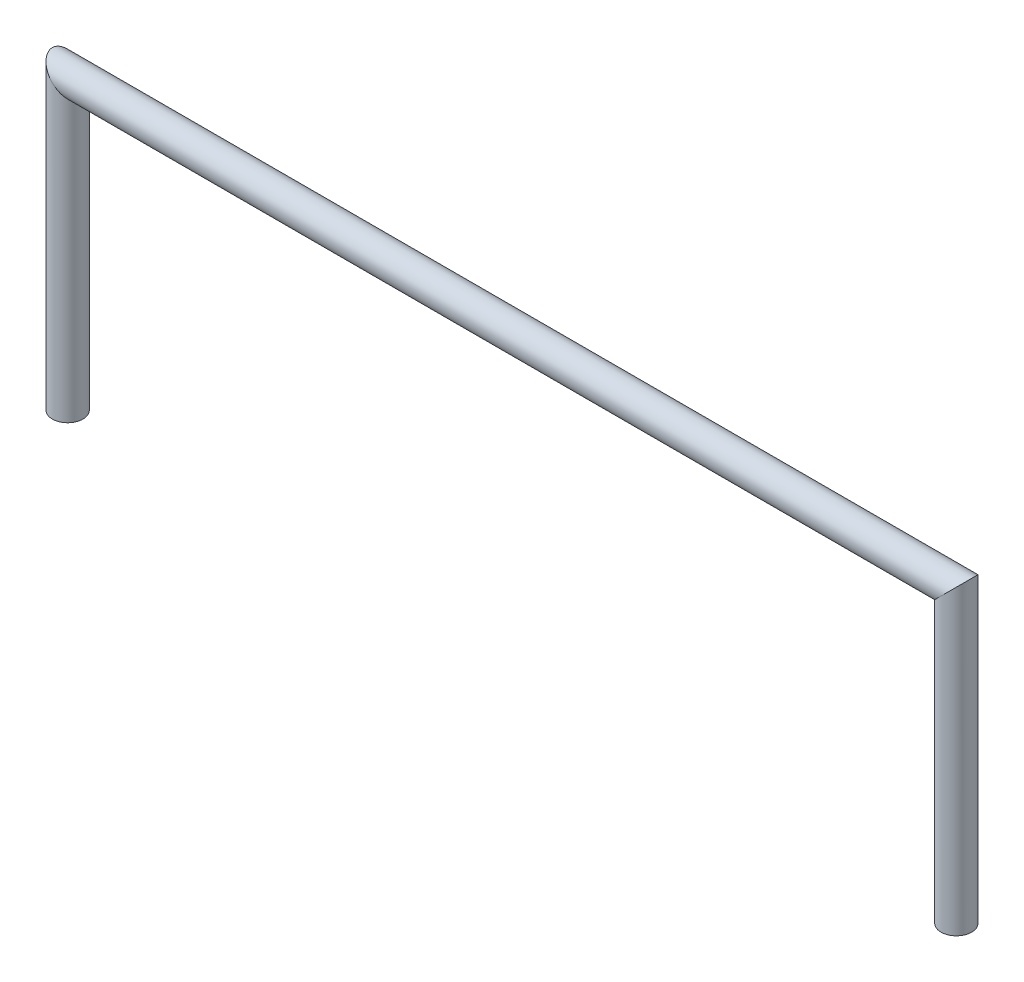
from build123d import *

# Parameters (mm, degrees)
SKETCH3_R   = 12.7
SKETCH3_R_2 = 8.73125


with BuildPart() as part:
    # Sweep1: sweep along a path in Sketch1
    with BuildLine(Plane.XY) as sweep1_path:
        Line((0, 0), (0, 241.3))
        Line((0, 241.3), (736.6, 241.3))
        Line((736.6, 241.3), (736.6, 0))
    # Sketch3 → Sweep1 (sweep)
    with BuildSketch(Plane(origin=(0, 0, 0), x_dir=(1, 0, 0), z_dir=(0, 1, 0))):
        Circle(SKETCH3_R)
        Circle(SKETCH3_R_2, mode=Mode.SUBTRACT)
    sweep(path=sweep1_path.line, transition=Transition.RIGHT)


solid = part.part
